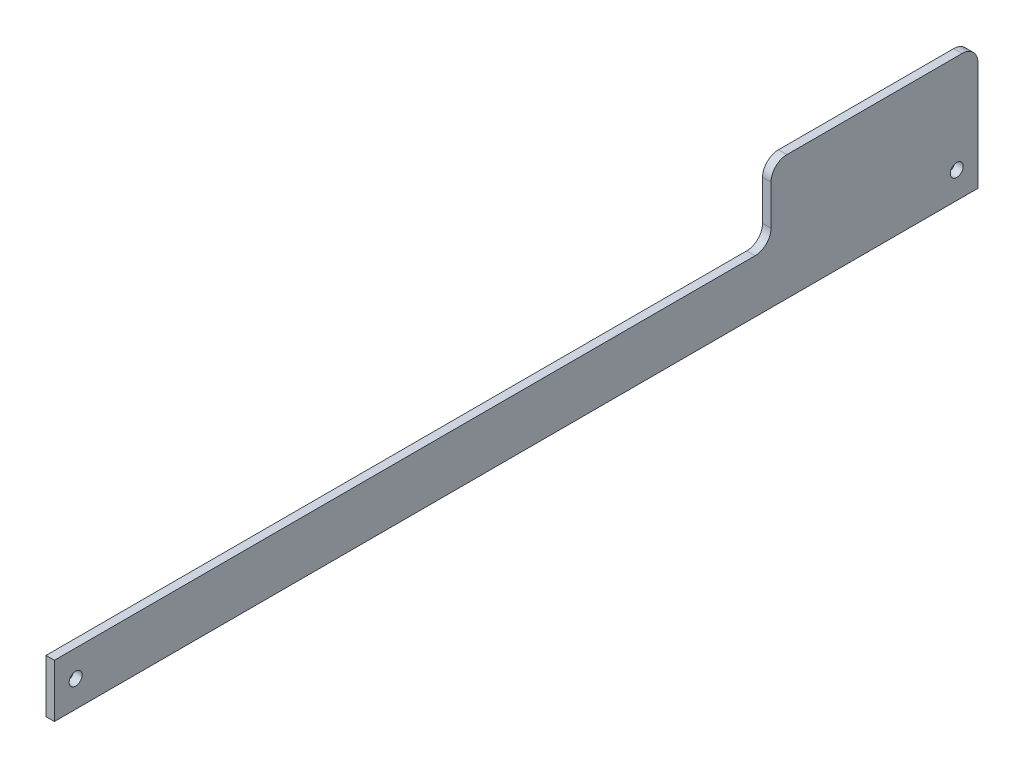
from build123d import *

# Parameters (mm, degrees)
BOSS_EXTRUDE1_DEPTH   = 1.5875
F_2_CLEARANCE_HOLE1_D = 2.4384
FILLET1_R             = 3


with BuildPart() as part:
    # Sketch1 → Boss-Extrude1 (new body)
    with BuildSketch(Plane(origin=(0, 0, 0), x_dir=(0, 0, -1), z_dir=(1, 0, 0))):
        Polygon((0, 0), (174, 0), (174, 23.5), (135, 23.5), (135, 10), (0, 10), align=None)
    extrude(amount=BOSS_EXTRUDE1_DEPTH)

    # #2 Clearance Hole1 (through all)
    with Locations(Plane(origin=(1.5875, 0, 0), x_dir=(0, 0, -1), z_dir=(1, 0, 0))):
        with Locations((4, 5), (170, 5)):
            Hole(F_2_CLEARANCE_HOLE1_D / 2)

    # Fillet1
    fillet1_edges = [part.edges().sort_by_distance(p)[0] for p in [
        (0.79375, 10, -135),
        (0.79375, 23.5, -135),
        (0.79375, 23.5, -174),
    ]]
    fillet(fillet1_edges, radius=FILLET1_R)


solid = part.part
